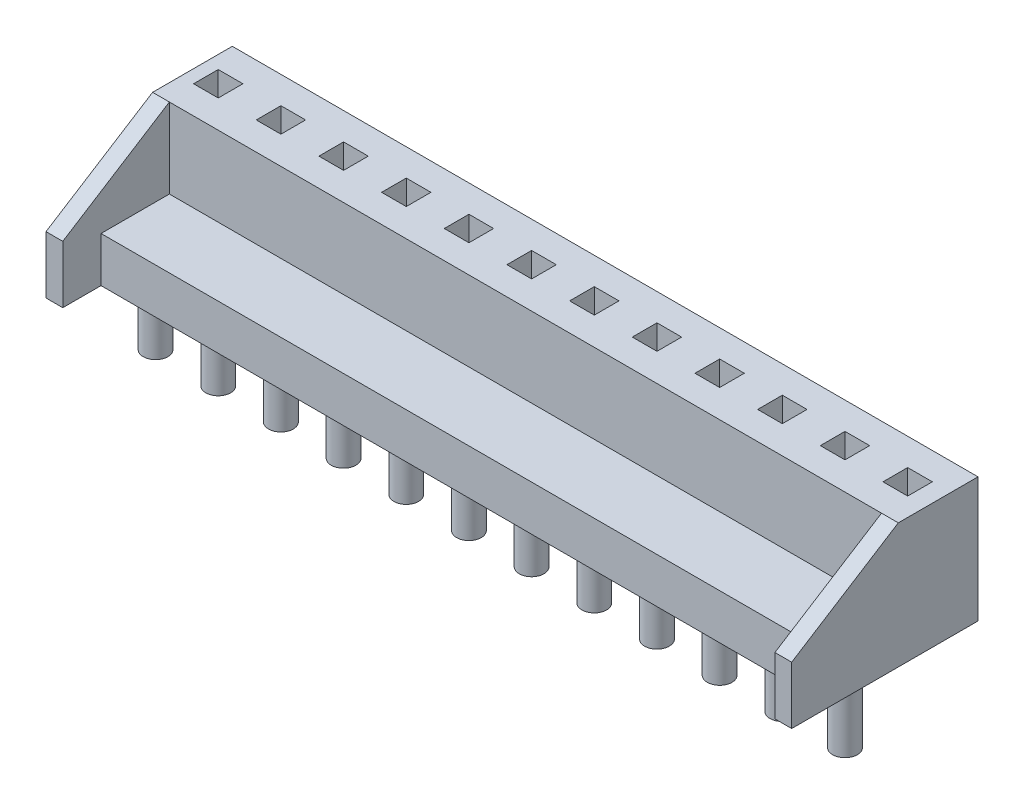
from build123d import *

# Parameters (mm, degrees)
BOSS_EXTRUDE1_DEPTH = 15.11
BOSS_EXTRUDE2_DEPTH = 0.68
SKETCH3_W           = 1
SKETCH3_H           = 1
CUT_EXTRUDE1_DEPTH  = 6.06
SKETCH4_R           = 0.5
BOSS_EXTRUDE3_DEPTH = 3
LPATTERN1_COUNT     = 12
LPATTERN1_PITCH     = 2.54


with BuildPart() as part:
    # Sketch1 → Boss-Extrude1 (new body, symmetric)
    with BuildSketch(Plane(origin=(0, 0, 0), x_dir=(0, 0, -1), z_dir=(1, 0, 0))):
        Polygon((-2.77, 0), (3.23, 0), (3.23, 5.06), (0, 5.06), (0, 1.83), (-2.77, 1.83), align=None)
    extrude(amount=BOSS_EXTRUDE1_DEPTH, both=True)

    # Sketch2 → Boss-Extrude2 (add)
    with BuildSketch(Plane(origin=(15.11, 0, 0), x_dir=(0, 0, -1), z_dir=(1, 0, 0))):
        Polygon((-4.32, 0), (-4.32, 2.33), (0, 5.06), (0, 0), align=None)
    boss_extrude2 = extrude(amount=-BOSS_EXTRUDE2_DEPTH)

    # Mirror1: Boss-Extrude2 across plane
    add(boss_extrude2.mirror(Plane(origin=(0, 0, 0), x_dir=(0, 0, 1), z_dir=(1, 0, 0))))

    # Sketch3 → Cut-Extrude1 (cut, through all)
    with BuildSketch(Plane(origin=(0, 5.06, 0), x_dir=(1, 0, 0), z_dir=(0, 1, 0))):
        with Locations((13.86, 1.63)):
            Rectangle(SKETCH3_W, SKETCH3_H)
    cut_extrude1 = extrude(amount=-CUT_EXTRUDE1_DEPTH, mode=Mode.SUBTRACT)

    # Sketch4 → Boss-Extrude3 (add)
    with BuildSketch(Plane(origin=(0, 0, 0), x_dir=(1, 0, 0), z_dir=(0, 1, 0))):
        with Locations((13.86, -0.91)):
            Circle(SKETCH4_R)
    boss_extrude3 = extrude(amount=-BOSS_EXTRUDE3_DEPTH)

    # LPattern1: Cut-Extrude1, Boss-Extrude3 ×12
    with Locations(*[(-i * LPATTERN1_PITCH, 0, 0) for i in range(1, LPATTERN1_COUNT)]):
        add(cut_extrude1, mode=Mode.SUBTRACT)
        add(boss_extrude3)


solid = part.part
